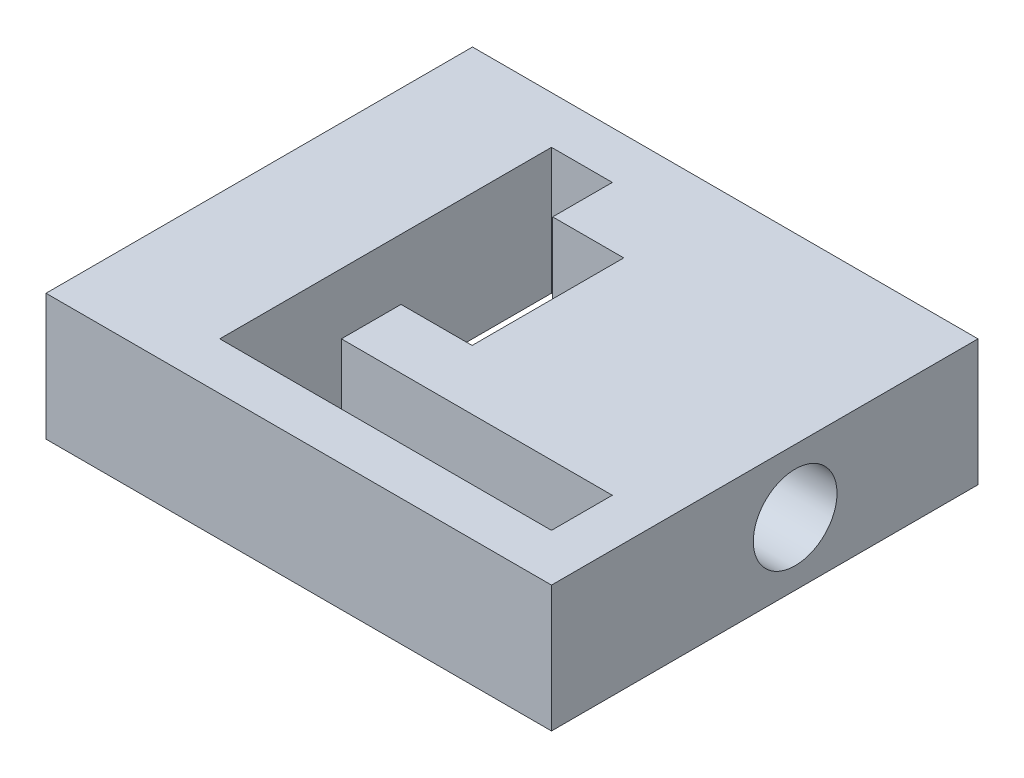
from build123d import *

# Parameters (mm, degrees)
SKETCH1_W           = 27
SKETCH1_H           = 27
BOSS_EXTRUDE1_DEPTH = 8
SKETCH2_W           = 4.5
SKETCH2_H           = 9.6
CUT_EXTRUDE1_DEPTH  = 9
SKETCH3_R           = 2.65
CUT_EXTRUDE2_DEPTH  = 15.65
SKETCH4_W           = 27
SKETCH4_H           = 8
SKETCH4_R           = 1.25
BOSS_EXTRUDE2_DEPTH = 5


with BuildPart() as part:
    # Sketch1 → Boss-Extrude1 (new body)
    with BuildSketch(Plane(origin=(0, 0, 0), x_dir=(1, 0, 0), z_dir=(0, 1, 0))):
        with Locations((13.5, 13.5)):
            Rectangle(SKETCH1_W, SKETCH1_H)
        Polygon((3, 24), (3, 3), (24, 3), (24, 6.85), (6.85, 6.85), (6.85, 24), align=None, mode=Mode.SUBTRACT)
    extrude(amount=BOSS_EXTRUDE1_DEPTH)

    # Sketch2 → Cut-Extrude1 (cut, through all)
    with BuildSketch(Plane(origin=(0, 8, 0), x_dir=(1, 0, 0), z_dir=(0, 1, 0))):
        with Locations((9.1, 15.425)):
            Rectangle(SKETCH2_W, SKETCH2_H)
    extrude(amount=-CUT_EXTRUDE1_DEPTH, mode=Mode.SUBTRACT)

    # Sketch3 → Cut-Extrude2 (cut)
    with BuildSketch(Plane(origin=(27, 0, 0), x_dir=(0, 0, -1), z_dir=(1, 0, 0))):
        with Locations((15.425, 4)):
            Circle(SKETCH3_R)
    extrude(amount=-CUT_EXTRUDE2_DEPTH, mode=Mode.SUBTRACT)

    # Sketch4 → Boss-Extrude2 (add)
    with BuildSketch(Plane.ZY):
        with Locations((-13.5, 4)):
            Rectangle(SKETCH4_W, SKETCH4_H)
        with Locations((-22.78, 5)):
            Circle(SKETCH4_R, mode=Mode.SUBTRACT)
        with Locations((-4.22, 5)):
            Circle(SKETCH4_R, mode=Mode.SUBTRACT)
    extrude(amount=BOSS_EXTRUDE2_DEPTH)


solid = part.part
